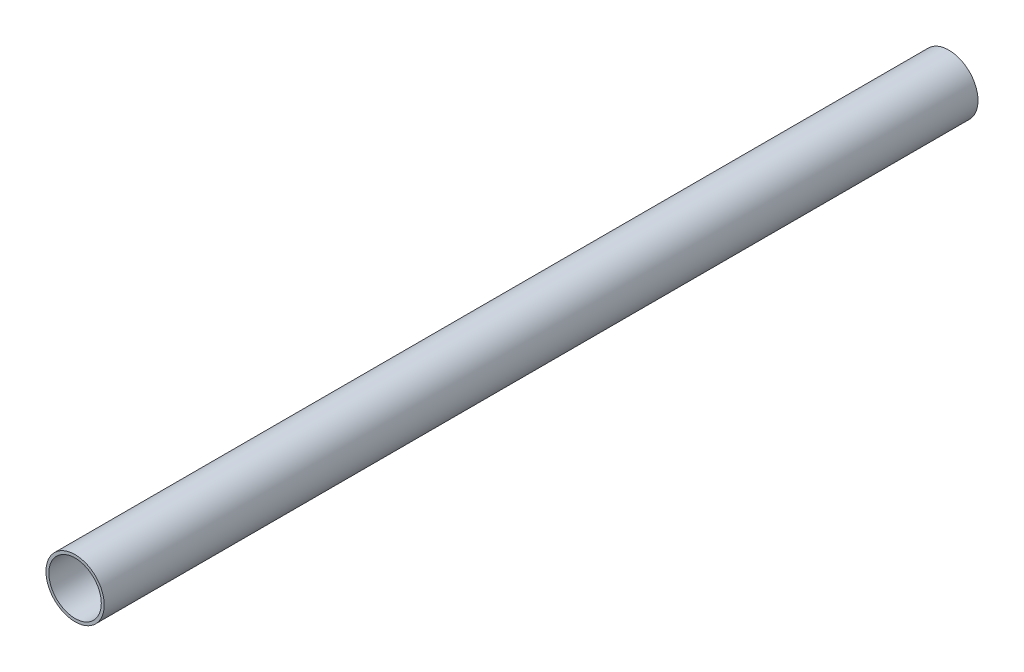
from build123d import *

# Parameters (mm, degrees)
ESQUISSE1_R        = 5
ESQUISSE1_R_2      = 4.5
BOSS_EXTRU_1_DEPTH = 150


with BuildPart() as part:
    # Esquisse1 → Boss.-Extru.1 (new body)
    with BuildSketch(Plane.XY):
        Circle(ESQUISSE1_R)
        Circle(ESQUISSE1_R_2, mode=Mode.SUBTRACT)
    extrude(amount=BOSS_EXTRU_1_DEPTH)


solid = part.part
